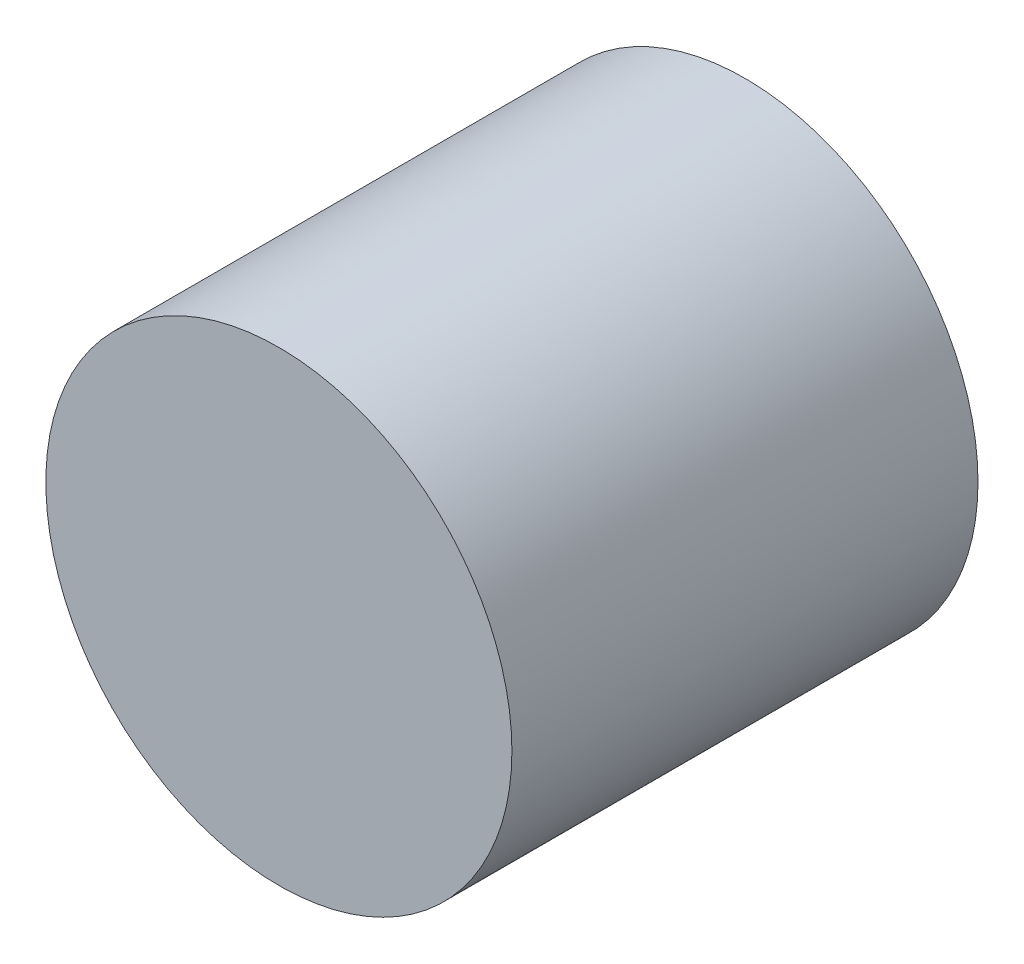
from build123d import *

# Parameters (mm, degrees)
SKETCH1_R           = 3.5
BOSS_EXTRUDE1_DEPTH = 7
SKETCH2_R           = 2.75
CUT_EXTRUDE1_DEPTH  = 4.5


with BuildPart() as part:
    # Sketch1 → Boss-Extrude1 (new body)
    with BuildSketch(Plane.XY):
        Circle(SKETCH1_R)
    extrude(amount=BOSS_EXTRUDE1_DEPTH)

    # Sketch2 → Cut-Extrude1 (cut)
    with BuildSketch(Plane(origin=(0, 0, 0), x_dir=(-1, 0, 0), z_dir=(0, 0, -1))):
        Circle(SKETCH2_R)
    extrude(amount=-CUT_EXTRUDE1_DEPTH, mode=Mode.SUBTRACT)


solid = part.part
